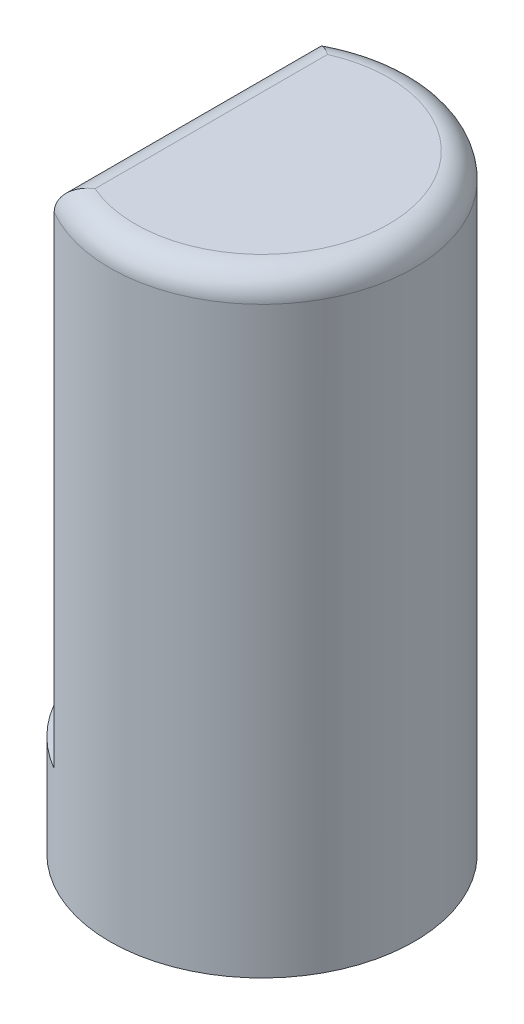
from build123d import *

# Parameters (mm, degrees)
SKETCH1_R           = 3
BOSS_EXTRUDE1_DEPTH = 12
SKETCH4_W           = 3.217642032
SKETCH4_H           = 5.196152422
CUT_EXTRUDE1_DEPTH  = 10
FILLET1_R           = 0.5


with BuildPart() as part:
    # Sketch1 → Boss-Extrude1 (new body)
    with BuildSketch(Plane(origin=(0, 0, 0), x_dir=(1, 0, 0), z_dir=(0, 1, 0))):
        Circle(SKETCH1_R)
    extrude(amount=BOSS_EXTRUDE1_DEPTH)

    # Sketch4 → Cut-Extrude1 (cut)
    with BuildSketch(Plane(origin=(0, 12, 0), x_dir=(1, 0, 0), z_dir=(0, 1, 0))):
        with Locations((-3.108821016, 0)):
            Rectangle(SKETCH4_W, SKETCH4_H)
    extrude(amount=-CUT_EXTRUDE1_DEPTH, mode=Mode.SUBTRACT)

    # Fillet1
    fillet1_edges = [part.edges().sort_by_distance(p)[0] for p in [
        (1.5, 12, 2.598076211),
        (-1.5, 12, 0),
    ]]
    fillet(fillet1_edges, radius=FILLET1_R)


solid = part.part
